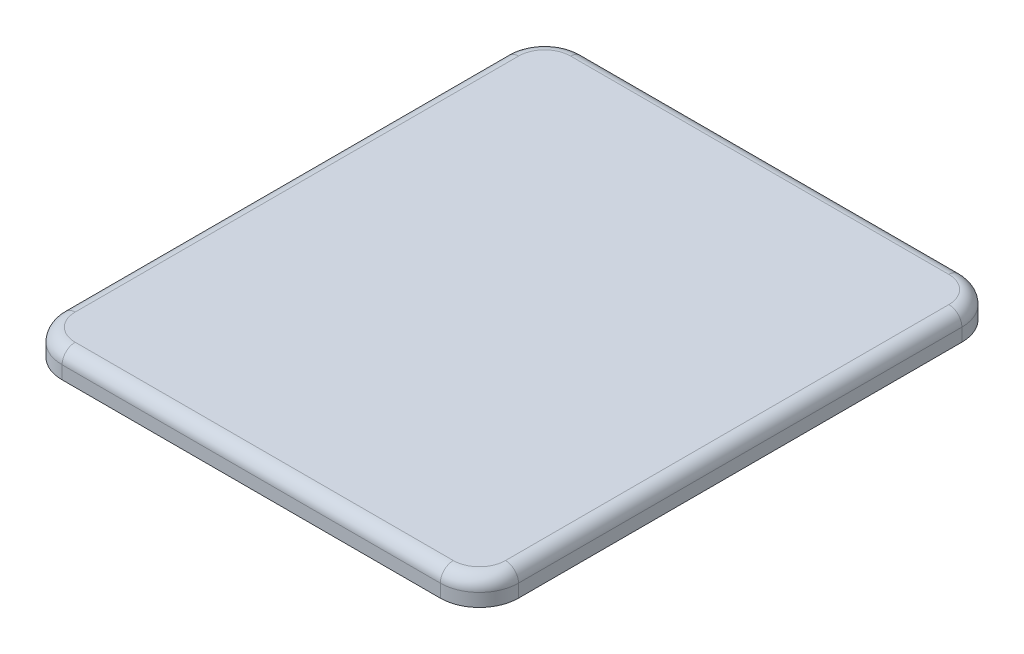
from build123d import *

# Parameters (mm, degrees)
BOSS_EXTRUDE1_DEPTH = 20
FILLET1_R           = 10


with BuildPart() as part:
    # Sketch1 → Boss-Extrude1 (new body)
    with BuildSketch(Plane(origin=(0, 0, 0), x_dir=(1, 0, 0), z_dir=(0, 1, 0))):
        with BuildLine():
            Line((-145, -200), (145, -200))
            ThreePointArc((145, -200), (166.213203436, -191.213203436), (175, -170))
            Line((175, -170), (175, 170))
            ThreePointArc((175, 170), (166.213203436, 191.213203436), (145, 200))
            Line((145, 200), (-145, 200))
            ThreePointArc((-145, 200), (-166.213203436, 191.213203436), (-175, 170))
            Line((-175, 170), (-175, -170))
            ThreePointArc((-175, -170), (-166.213203436, -191.213203436), (-145, -200))
        make_face()
    extrude(amount=BOSS_EXTRUDE1_DEPTH)

    # Fillet1
    fillet1_edges = [part.edges().sort_by_distance(p)[0] for p in [
        (166.213203436, 20, 191.213203436),
        (175, 20, 0),
        (166.213203436, 20, -191.213203436),
        (0, 20, -200),
        (-166.213203436, 20, -191.213203436),
        (-175, 20, 0),
        (-166.213203436, 20, 191.213203436),
        (0, 20, 200),
    ]]
    fillet(fillet1_edges, radius=FILLET1_R)


solid = part.part
